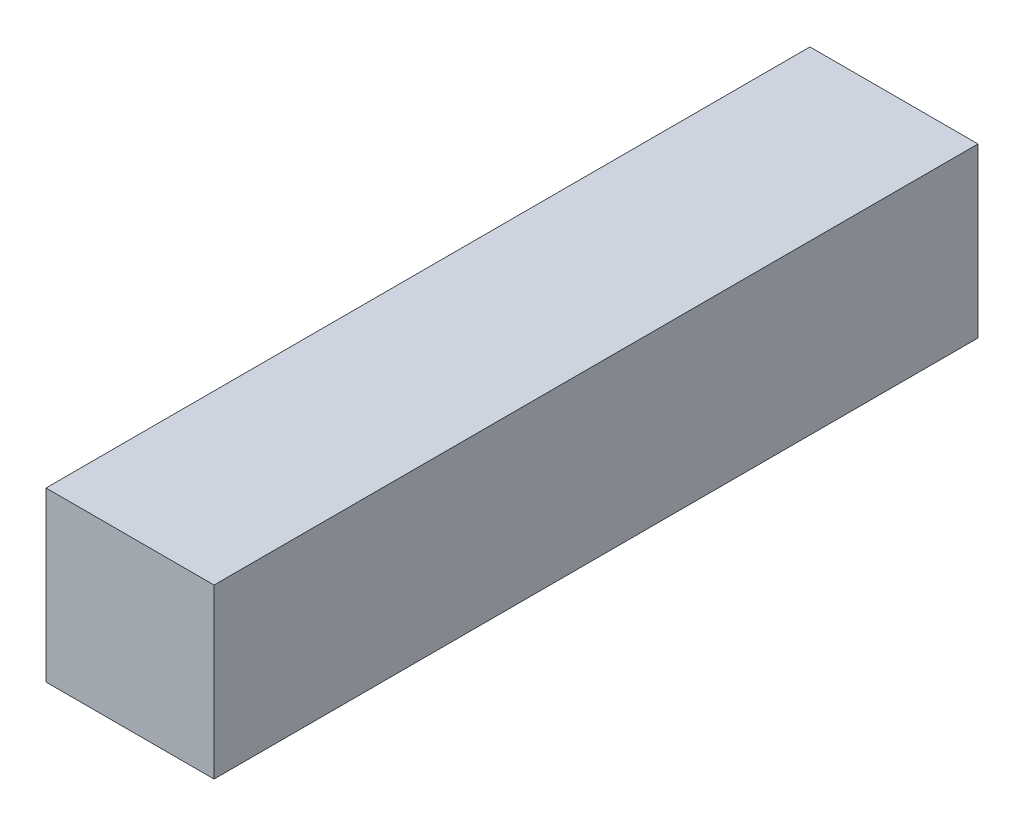
from build123d import *

# Parameters (mm, degrees)
ESQUISSE1_W        = 22
ESQUISSE1_H        = 22
BOSS_EXTRU_1_DEPTH = 100


with BuildPart() as part:
    # Esquisse1 → Boss.-Extru.1 (new body)
    with BuildSketch(Plane.XY):
        Rectangle(ESQUISSE1_W, ESQUISSE1_H)
    extrude(amount=BOSS_EXTRU_1_DEPTH)


solid = part.part
